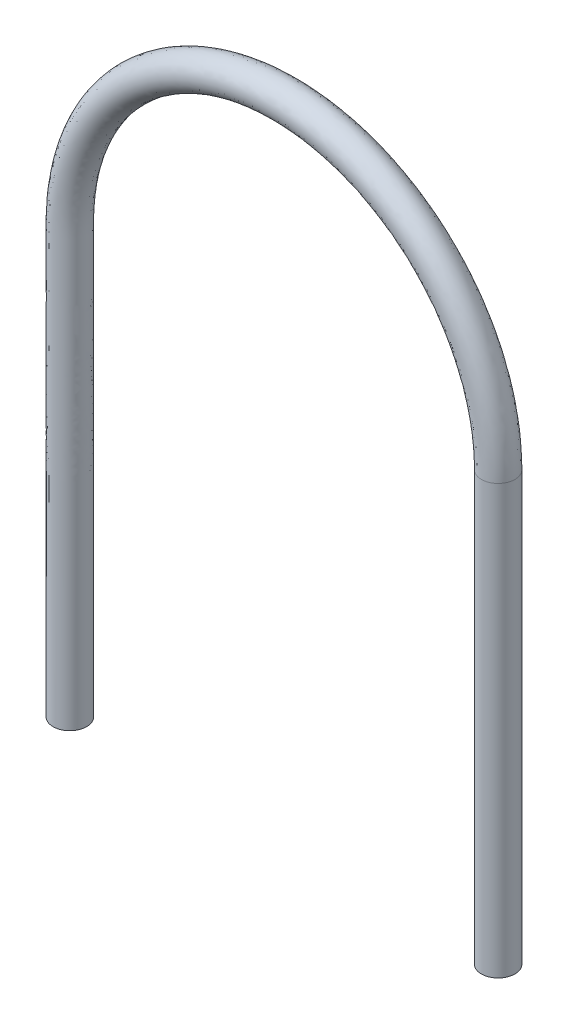
from build123d import *

# Parameters (mm, degrees)
SKETCH2_R = 12.7
SKETCH3_R = 9.525


with BuildPart() as part:
    # Sweep2: sweep along a path in Sketch1
    with BuildLine(Plane.XY) as sweep2_path:
        Line((0, -323.85), (0, 0))
        ThreePointArc((0, 0), (161.925, 161.925), (323.85, 0))
        Line((323.85, 0), (323.85, -323.85))
    # Sketch2 → Sweep2 (sweep)
    with BuildSketch(Plane(origin=(0, 0, 0), x_dir=(1, 0, 0), z_dir=(0, 1, 0))):
        Circle(SKETCH2_R)
    sweep(path=sweep2_path.line)

    # Cut-Sweep1: sweep along a path in Sketch1_6
    with BuildLine(Plane.XY) as cut_sweep1_path:
        Line((0, -323.85), (0, 0))
        ThreePointArc((0, 0), (161.925, 161.925), (323.85, 0))
        Line((323.85, 0), (323.85, -323.85))
    # Sketch3 → Cut-Sweep1 (sweep, cut)
    with BuildSketch(Plane(origin=(0, 0, 0), x_dir=(1, 0, 0), z_dir=(0, 1, 0))):
        Circle(SKETCH3_R)
    sweep(path=cut_sweep1_path.line, mode=Mode.SUBTRACT)


solid = part.part
